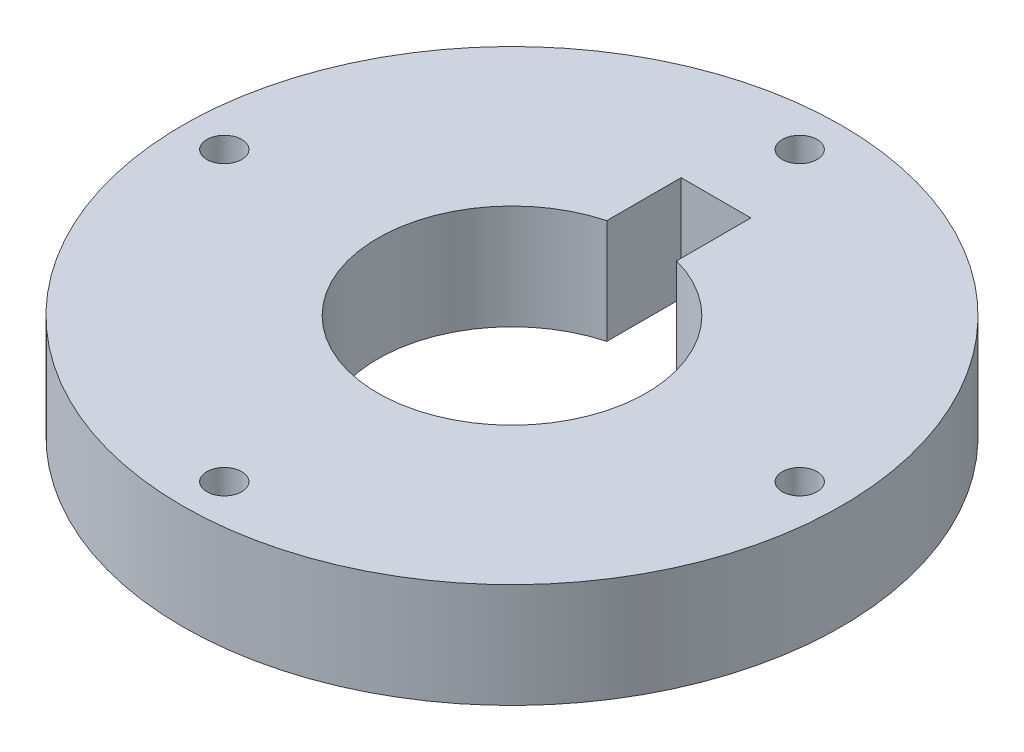
from build123d import *

# Parameters (mm, degrees)
SKETCH1_R           = 47.25
SKETCH1_R_2         = 2.5
BOSS_EXTRUDE1_DEPTH = 15


with BuildPart() as part:
    # Sketch1 → Boss-Extrude1 (new body)
    with BuildSketch(Plane(origin=(0, 0, 0), x_dir=(1, 0, 0), z_dir=(0, 1, 0))):
        Circle(SKETCH1_R)
        with Locations((0, 41.25)):
            Circle(SKETCH1_R_2, mode=Mode.SUBTRACT)
        with Locations((41.25, 0)):
            Circle(SKETCH1_R_2, mode=Mode.SUBTRACT)
        with Locations((0, -41.25)):
            Circle(SKETCH1_R_2, mode=Mode.SUBTRACT)
        with Locations((-41.25, 0)):
            Circle(SKETCH1_R_2, mode=Mode.SUBTRACT)
        with BuildLine():
            Line((-5, 18.589311445), (-5, 29.25))
            Line((-5, 29.25), (5, 29.25))
            Line((5, 29.25), (5, 18.589311445))
            ThreePointArc((5, 18.589311445), (0, -19.25), (-5, 18.589311445))
        make_face(mode=Mode.SUBTRACT)
    extrude(amount=BOSS_EXTRUDE1_DEPTH)


solid = part.part
